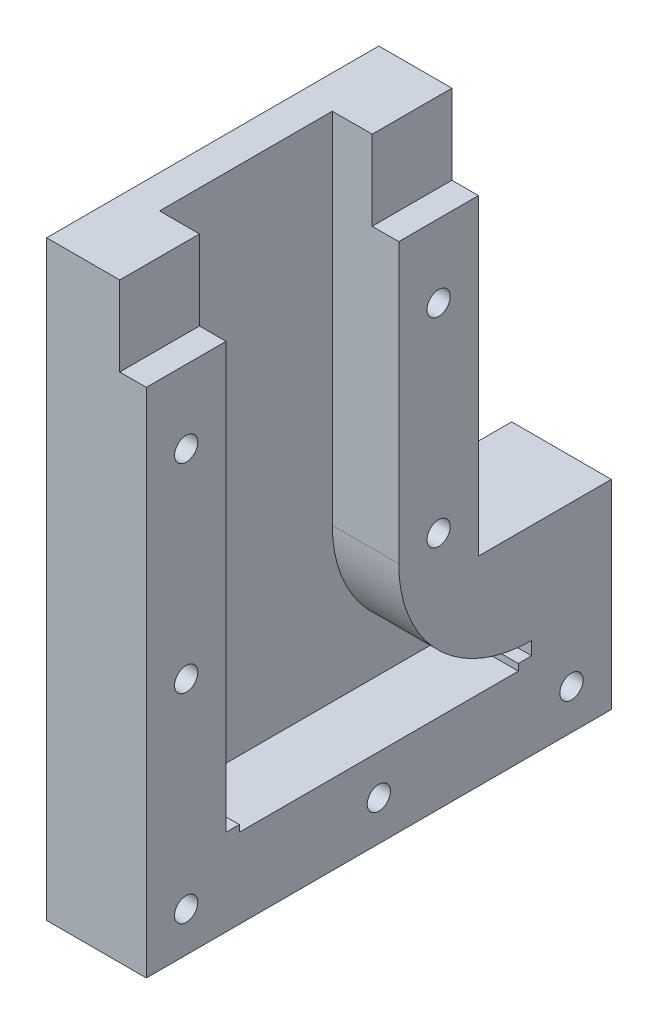
from build123d import *

# Parameters (mm, degrees)
EXTRUDE_2_DEPTH     = 15
SKETCH_4_W          = 26
SKETCH_4_H          = 77
CUT_EXTRUDE_3_DEPTH = 10
CUT_EXTRUDE_5_DEPTH = 10
SKETCH_6_W          = 12
SKETCH_6_H          = 12
CUT_EXTRUDE_6_DEPTH = 4
SKETCH_7_W          = 2
SKETCH_7_H          = 2
EXTRUDE_5_DEPTH     = 3
SKETCH_8_W          = 2
SKETCH_8_H          = 1
EXTRUDE_6_DEPTH     = 7
SKETCH_9_R          = 1.75
CUT_EXTRUDE_7_DEPTH = 16


with BuildPart() as part:
    # ｽｹｯﾁ1 → ﾎﾞｽ - 押し出し2 (new body)
    with BuildSketch(Plane(origin=(0, 0, 0), x_dir=(0, 0, -1), z_dir=(1, 0, 0))):
        Polygon((25, 44.5), (25, -14.5), (45, -14.5), (45, -44.5), (25, -44.5), (-25, -44.5), (-25, 44.5), align=None)
    extrude(amount=EXTRUDE_2_DEPTH)

    # ｽｹｯﾁ4 → ｶｯﾄ - 押し出し3 (cut)
    with BuildSketch(Plane(origin=(15, 0, 0), x_dir=(0, 0, -1), z_dir=(1, 0, 0))):
        with Locations((0, 6)):
            Rectangle(SKETCH_4_W, SKETCH_4_H)
    extrude(amount=-CUT_EXTRUDE_3_DEPTH, mode=Mode.SUBTRACT)

    # ｽｹｯﾁ5 → ｶｯﾄ - 押し出し5 (cut)
    with BuildSketch(Plane(origin=(15, 0, 0), x_dir=(0, 0, -1), z_dir=(1, 0, 0))):
        with BuildLine():
            Line((13, -32.5), (13, -9.5))
            ThreePointArc((13, -9.5), (18.857864376, -23.642135624), (33, -29.5))
            Line((33, -29.5), (33, -32.5))
            Line((33, -32.5), (13, -32.5))
        make_face()
    extrude(amount=-CUT_EXTRUDE_5_DEPTH, mode=Mode.SUBTRACT)

    # ｽｹｯﾁ6 → ｶｯﾄ - 押し出し6 (cut)
    with BuildSketch(Plane(origin=(15, 0, 0), x_dir=(0, 0, -1), z_dir=(1, 0, 0))):
        with Locations((-19, 38.5)):
            Rectangle(SKETCH_6_W, SKETCH_6_H)
        with Locations((19, 38.5)):
            Rectangle(SKETCH_6_W, SKETCH_6_H)
    extrude(amount=-CUT_EXTRUDE_6_DEPTH, mode=Mode.SUBTRACT)

    # ｽｹｯﾁ7 → ﾎﾞｽ - 押し出し5 (add)
    with BuildSketch(Plane(origin=(5, 0, 0), x_dir=(0, 0, -1), z_dir=(1, 0, 0))):
        with Locations((-12, -31.5)):
            Rectangle(SKETCH_7_W, SKETCH_7_H)
        with Locations((32, -31.5)):
            Rectangle(SKETCH_7_W, SKETCH_7_H)
    extrude(amount=EXTRUDE_5_DEPTH)

    # ｽｹｯﾁ8 → ﾎﾞｽ - 押し出し6 (add)
    with BuildSketch(Plane(origin=(8, 0, 0), x_dir=(0, 0, -1), z_dir=(1, 0, 0))):
        with Locations((-12, -32)):
            Rectangle(SKETCH_8_W, SKETCH_8_H)
        with Locations((32, -32)):
            Rectangle(SKETCH_8_W, SKETCH_8_H)
    extrude(amount=EXTRUDE_6_DEPTH)

    # ｽｹｯﾁ9 → ｶｯﾄ - 押し出し7 (cut, through all)
    with BuildSketch(Plane(origin=(15, 0, 0), x_dir=(0, 0, -1), z_dir=(1, 0, 0))):
        with Locations((-19, 21.5)):
            Circle(SKETCH_9_R)
        with Locations((-19, -8.5)):
            Circle(SKETCH_9_R)
        with Locations((-19, -38.5)):
            Circle(SKETCH_9_R)
        with Locations((10, -38.5)):
            Circle(SKETCH_9_R)
        with Locations((39, -38.5)):
            Circle(SKETCH_9_R)
        with Locations((19, -8.5)):
            Circle(SKETCH_9_R)
        with Locations((19, 21.5)):
            Circle(SKETCH_9_R)
    extrude(amount=-CUT_EXTRUDE_7_DEPTH, mode=Mode.SUBTRACT)


solid = part.part
